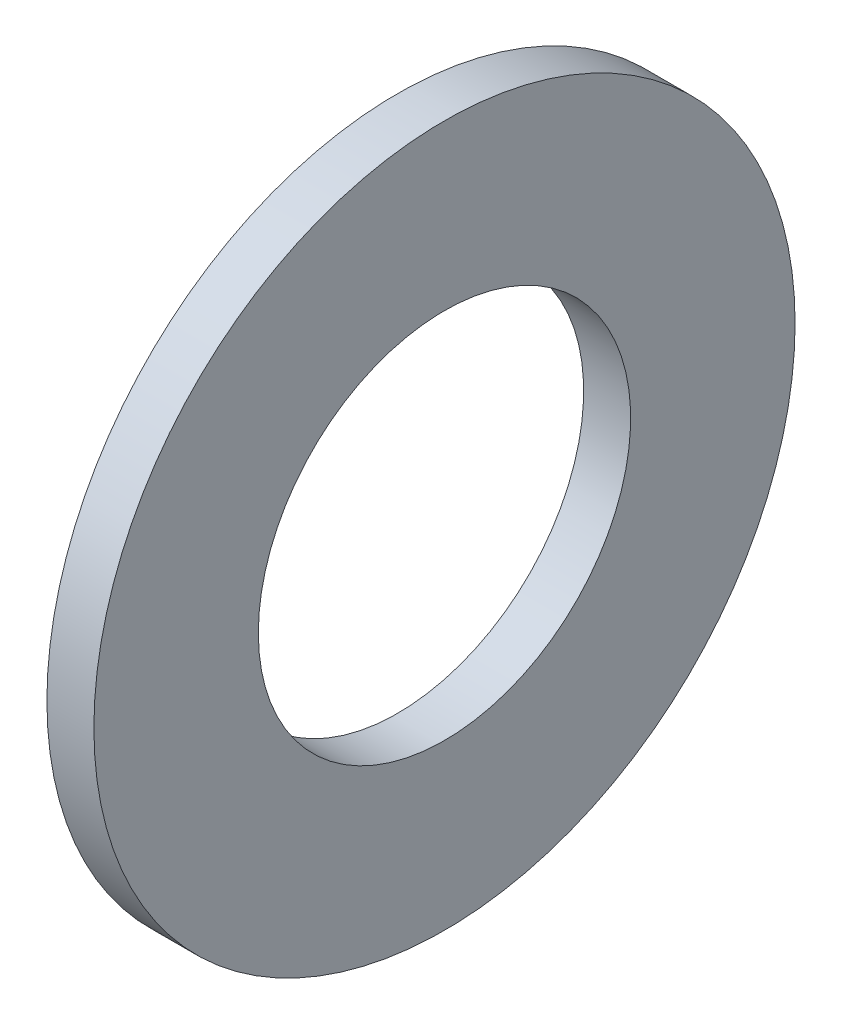
from build123d import *

# Parameters (mm, degrees)
SKETCH1_W = 3.4036
SKETCH1_H = 11.9126


with BuildPart() as part:
    # Sketch1 → Base-Revolve (revolve)
    with BuildSketch(Plane.XY):
        with Locations((-1.7018, 19.4437)):
            Rectangle(SKETCH1_W, SKETCH1_H)
    revolve(axis=Axis((-34.925, 0, 0), (1, 0, 0)))


solid = part.part
